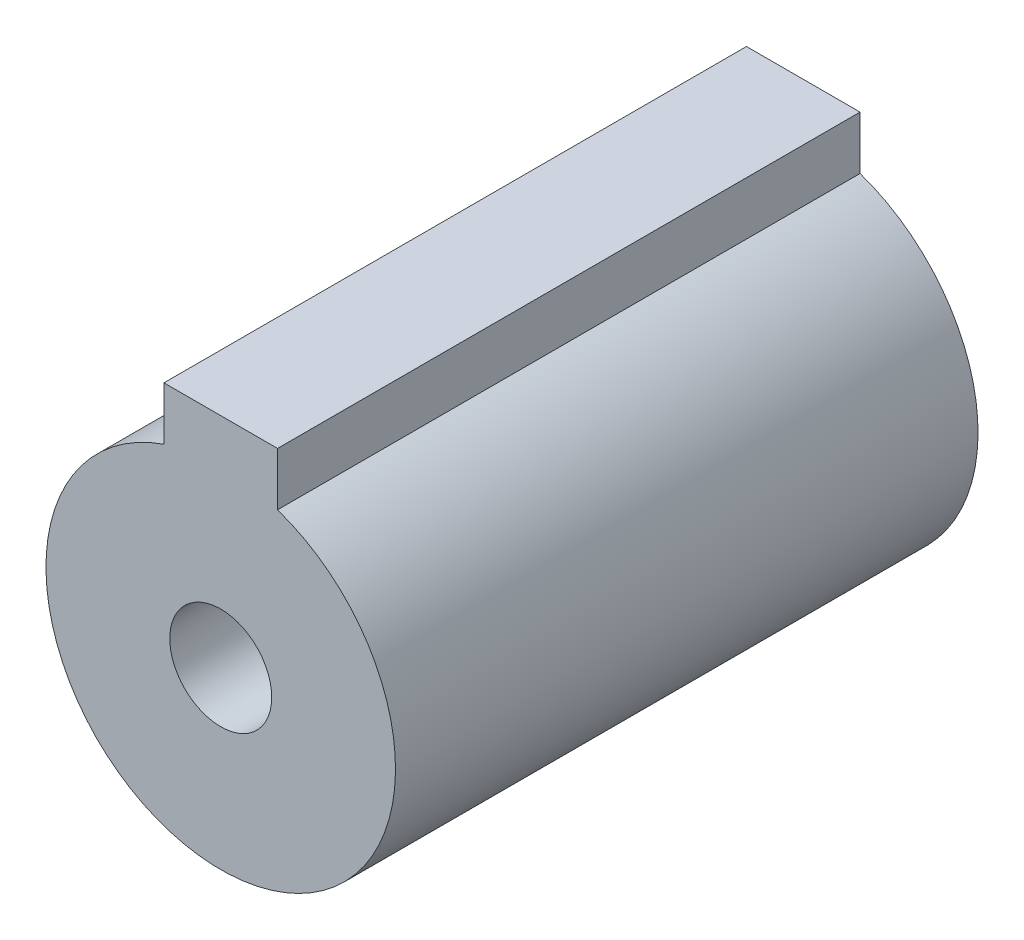
from build123d import *

# Parameters (mm, degrees)
ESQUISSE2_R             = 12
BOSS_EXTRU_1_DEPTH      = 40
ESQUISSE3_W             = 7.8
ESQUISSE3_H             = 4.051853135
BOSS_EXTRU_3_DEPTH      = 40
ESQUISSE4_R             = 9.5
ENL_V_MAT_EXTRU_3_DEPTH = 32
ESQUISSE6_W             = 6
ESQUISSE6_H             = 3.848056491
ENL_V_MAT_EXTRU_4_DEPTH = 32
ESQUISSE7_R             = 3.5
ENL_V_MAT_EXTRU_5_DEPTH = 42


with BuildPart() as part:
    # Esquisse2 → Boss.-Extru.1 (new body)
    with BuildSketch(Plane.XY):
        Circle(ESQUISSE2_R)
    extrude(amount=BOSS_EXTRU_1_DEPTH)

    # Esquisse3 → Boss.-Extru.3 (add)
    with BuildSketch(Plane.XY):
        with Locations((0, 12.974073433)):
            Rectangle(ESQUISSE3_W, ESQUISSE3_H)
    extrude(amount=BOSS_EXTRU_3_DEPTH)

    # Esquisse4 → Enlèv. mat.-Extru.3 (cut)
    with BuildSketch(Plane.XY):
        Circle(ESQUISSE4_R)
    extrude(amount=ENL_V_MAT_EXTRU_3_DEPTH, mode=Mode.SUBTRACT)

    # Esquisse6 → Enlèv. mat.-Extru.4 (cut)
    with BuildSketch(Plane.XY):
        with Locations((0, 10.275971755)):
            Rectangle(ESQUISSE6_W, ESQUISSE6_H)
    extrude(amount=ENL_V_MAT_EXTRU_4_DEPTH, mode=Mode.SUBTRACT)

    # Esquisse7 → Enlèv. mat.-Extru.5 (cut)
    with BuildSketch(Plane.XY):
        Circle(ESQUISSE7_R)
    extrude(amount=ENL_V_MAT_EXTRU_5_DEPTH, mode=Mode.SUBTRACT)


solid = part.part
